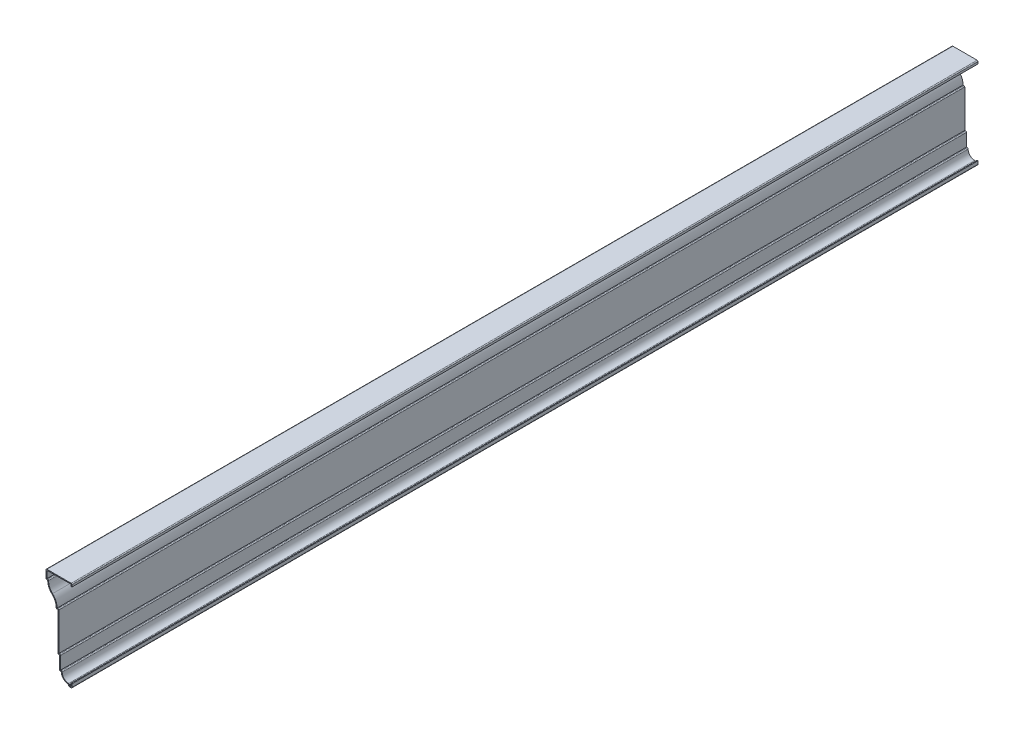
from build123d import *

# Parameters (mm, degrees)
EXTRUDE_THIN1_DEPTH = 1270
FILLET1_R           = 1.27


with BuildPart() as part:
    # Sketch1 → Extrude-Thin1 (new body)
    with BuildSketch(Plane.XY):
        with BuildLine():
            Line((0, 123.03125), (0, 127))
            Line((0, 127), (-36.5125, 127))
            Line((-36.5125, 127), (-36.5125, 114.3))
            Line((-36.5125, 114.3), (-34.13125, 114.3))
            ThreePointArc((-34.13125, 114.3), (-32.654718449, 106.700591974), (-28.1616931, 100.396317948))
            ThreePointArc((-28.1616931, 100.396317948), (-23.520818179, 93.737441229), (-22.225, 85.725))
            Line((-22.225, 85.725), (-19.84375, 85.725))
            Line((-19.84375, 85.725), (-19.84375, 31.75))
            Line((-19.84375, 31.75), (-17.4625, 31.75))
            Line((-17.4625, 31.75), (-17.4625, 12.7))
            Line((-17.4625, 12.7), (-15.08125, 12.7))
            ThreePointArc((-15.08125, 12.7), (-12.058958098, 5.403541902), (-4.7625, 2.38125))
            Line((-4.7625, 2.38125), (-4.7625, 0))
            Line((-4.7625, 0), (0, 0))
            Line((0, 0), (0, 5.55625))
            Line((0, 5.55625), (-1.27, 5.55625))
            Line((-1.27, 5.55625), (-1.27, 1.27))
            Line((-1.27, 1.27), (-3.4925, 1.27))
            Line((-3.4925, 1.27), (-3.4925, 3.740816077))
            ThreePointArc((-3.4925, 3.740816077), (-11.160932486, 6.301567514), (-13.721683923, 13.97))
            Line((-13.721683923, 13.97), (-16.1925, 13.97))
            Line((-16.1925, 13.97), (-16.1925, 33.02))
            Line((-16.1925, 33.02), (-18.57375, 33.02))
            Line((-18.57375, 33.02), (-18.57375, 86.995))
            Line((-18.57375, 86.995), (-20.918106783, 86.995))
            ThreePointArc((-20.918106783, 86.995), (-22.60788254, 94.835880545), (-27.307266754, 101.335921917))
            ThreePointArc((-27.307266754, 101.335921917), (-31.732733484, 107.803797872), (-32.783580599, 115.57))
            Line((-32.783580599, 115.57), (-35.2425, 115.57))
            Line((-35.2425, 115.57), (-35.2425, 125.73))
            Line((-35.2425, 125.73), (-1.27, 125.73))
            Line((-1.27, 125.73), (-1.27, 123.03125))
            Line((-1.27, 123.03125), (0, 123.03125))
        make_face()
    extrude(amount=-EXTRUDE_THIN1_DEPTH)

    # Fillet1
    fillet1_edges = [part.edges().sort_by_distance(p)[0] for p in [
        (-32.783580599, 115.57, -635),
        (-18.57375, 86.995, -635),
        (-16.1925, 33.02, -635),
        (-13.721683923, 13.97, -635),
        (-3.4925, 3.740816077, -635),
        (0, 0, -635),
        (-4.7625, 0, -635),
        (-17.4625, 12.7, -635),
        (-19.84375, 31.75, -635),
        (-22.225, 85.725, -635),
        (-36.5125, 114.3, -635),
        (-36.5125, 127, -635),
        (0, 127, -635),
    ]]
    fillet(fillet1_edges, radius=FILLET1_R)


solid = part.part
